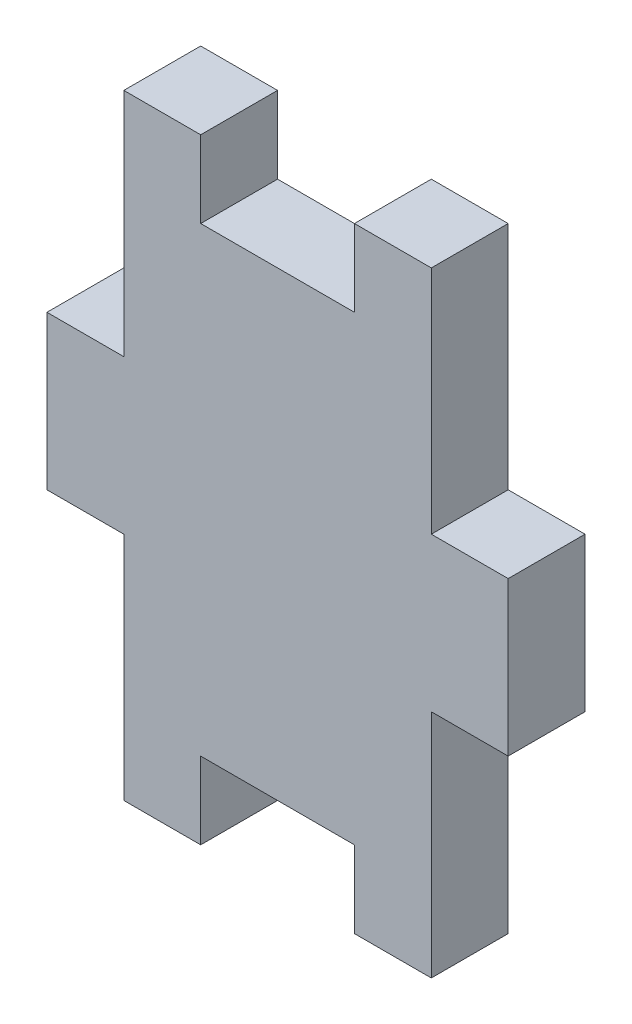
from build123d import *

# Parameters (mm, degrees)
EXTRUDE1_DEPTH = 3.175


with BuildPart() as part:
    # Sketch1 → Extrude1 (new body)
    with BuildSketch(Plane.XY):
        Polygon((-6.35, 12.7), (-3.175, 12.7), (-3.175, 9.525), (3.175, 9.525), (3.175, 12.7), (6.35, 12.7), (6.35, 3.175), (9.525, 3.175), (9.525, -3.175), (6.35, -3.175), (6.35, -12.7), (3.175, -12.7), (3.175, -9.525), (-3.175, -9.525), (-3.175, -12.7), (-6.35, -12.7), (-6.35, -3.175), (-9.525, -3.175), (-9.525, 3.175), (-6.35, 3.175), align=None)
    extrude(amount=EXTRUDE1_DEPTH)


solid = part.part
